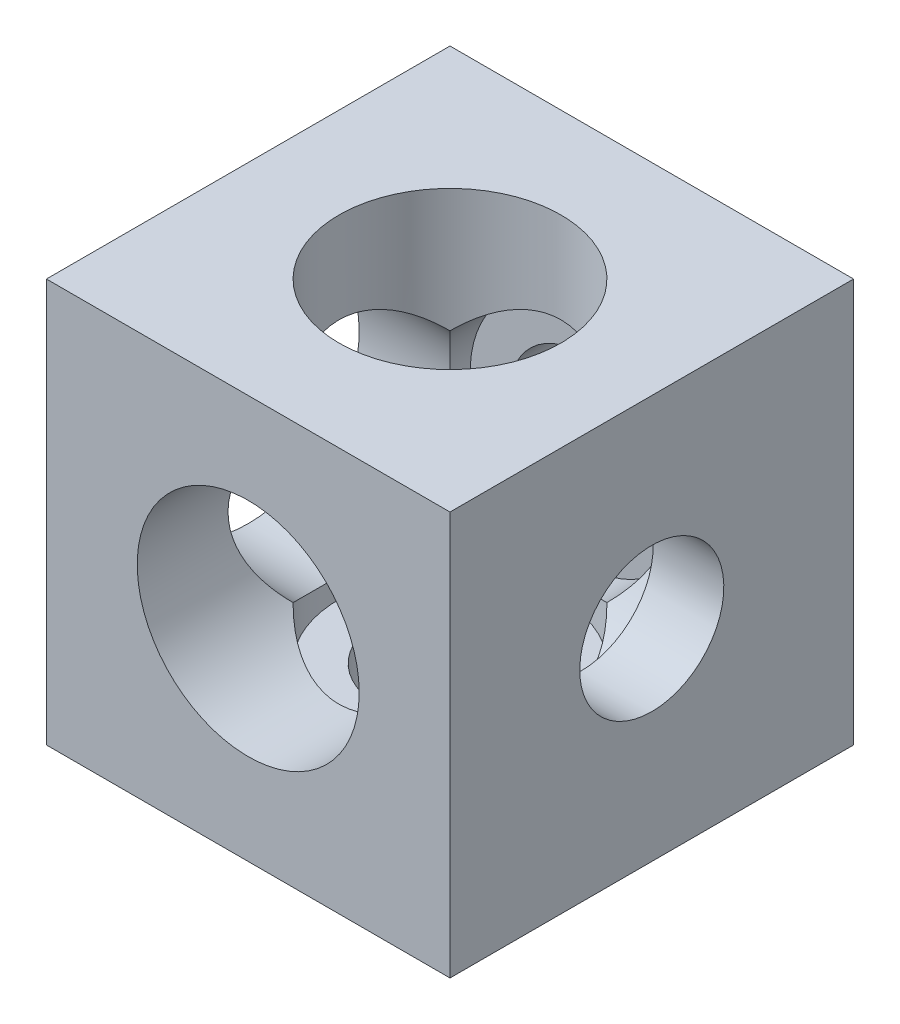
from build123d import *

# Parameters (mm, degrees)
SKETCH1_W           = 20
SKETCH1_H           = 20
BOSS_EXTRUDE1_DEPTH = 10
SKETCH2_R           = 3.57
CUT_EXTRUDE1_DEPTH  = 21
SKETCH3_R           = 5.5
CUT_EXTRUDE2_DEPTH  = 16.5
SKETCH4_R           = 3.57
CUT_EXTRUDE3_DEPTH  = 21
SKETCH5_R           = 5.5
CUT_EXTRUDE4_DEPTH  = 16.5
SKETCH6_R           = 3.57
CUT_EXTRUDE5_DEPTH  = 21
SKETCH7_R           = 5.5
CUT_EXTRUDE6_DEPTH  = 16.5


with BuildPart() as part:
    # Sketch1 → Boss-Extrude1 (new body, symmetric)
    with BuildSketch(Plane.XY):
        Rectangle(SKETCH1_W, SKETCH1_H)
    extrude(amount=BOSS_EXTRUDE1_DEPTH, both=True)

    # Sketch2 → Cut-Extrude1 (cut, through all)
    with BuildSketch(Plane.XY.offset(10)):
        Circle(SKETCH2_R)
    extrude(amount=-CUT_EXTRUDE1_DEPTH, mode=Mode.SUBTRACT)

    # Sketch3 → Cut-Extrude2 (cut)
    with BuildSketch(Plane.XY.offset(10)):
        Circle(SKETCH3_R)
    extrude(amount=-CUT_EXTRUDE2_DEPTH, mode=Mode.SUBTRACT)

    # Sketch4 → Cut-Extrude3 (cut, through all)
    with BuildSketch(Plane.ZY.offset(10)):
        Circle(SKETCH4_R)
    extrude(amount=-CUT_EXTRUDE3_DEPTH, mode=Mode.SUBTRACT)

    # Sketch5 → Cut-Extrude4 (cut)
    with BuildSketch(Plane.ZY.offset(10)):
        Circle(SKETCH5_R)
    extrude(amount=-CUT_EXTRUDE4_DEPTH, mode=Mode.SUBTRACT)

    # Sketch6 → Cut-Extrude5 (cut, through all)
    with BuildSketch(Plane(origin=(0, 10, 0), x_dir=(1, 0, 0), z_dir=(0, 1, 0))):
        Circle(SKETCH6_R)
    extrude(amount=-CUT_EXTRUDE5_DEPTH, mode=Mode.SUBTRACT)

    # Sketch7 → Cut-Extrude6 (cut)
    with BuildSketch(Plane(origin=(0, 10, 0), x_dir=(1, 0, 0), z_dir=(0, 1, 0))):
        Circle(SKETCH7_R)
    extrude(amount=-CUT_EXTRUDE6_DEPTH, mode=Mode.SUBTRACT)


solid = part.part
